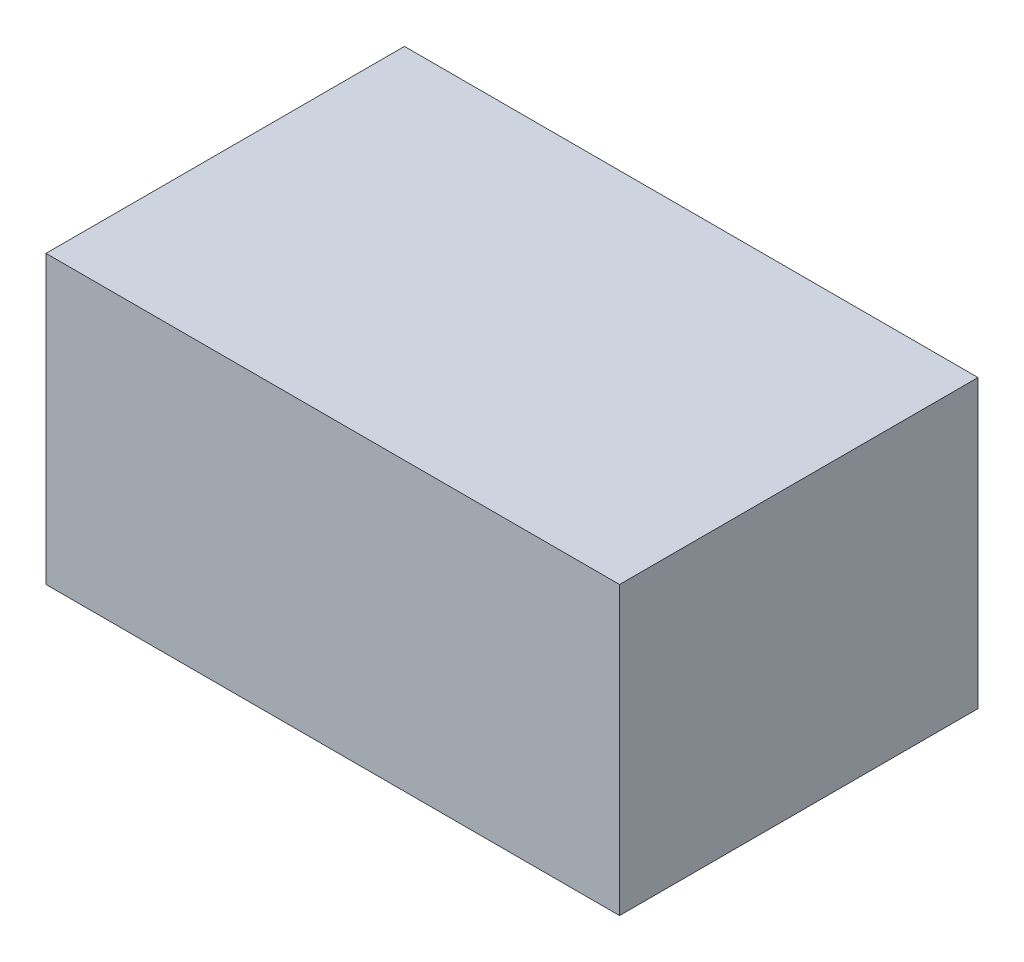
from build123d import *

# Parameters (mm, degrees)
SKETCH2_W           = 80
SKETCH2_H           = 50
BOSS_EXTRUDE1_DEPTH = 40
SKETCH3_W           = 68
SKETCH3_H           = 38
CUT_EXTRUDE1_DEPTH  = 6


with BuildPart() as part:
    # Sketch2 → Boss-Extrude1 (new body)
    with BuildSketch(Plane(origin=(0, 0, 0), x_dir=(1, 0, 0), z_dir=(0, 1, 0))):
        Rectangle(SKETCH2_W, SKETCH2_H)
    extrude(amount=BOSS_EXTRUDE1_DEPTH)

    # Sketch3 → Cut-Extrude1 (cut)
    with BuildSketch(Plane.XZ):
        Rectangle(SKETCH3_W, SKETCH3_H)
    extrude(amount=-CUT_EXTRUDE1_DEPTH, mode=Mode.SUBTRACT)


solid = part.part
